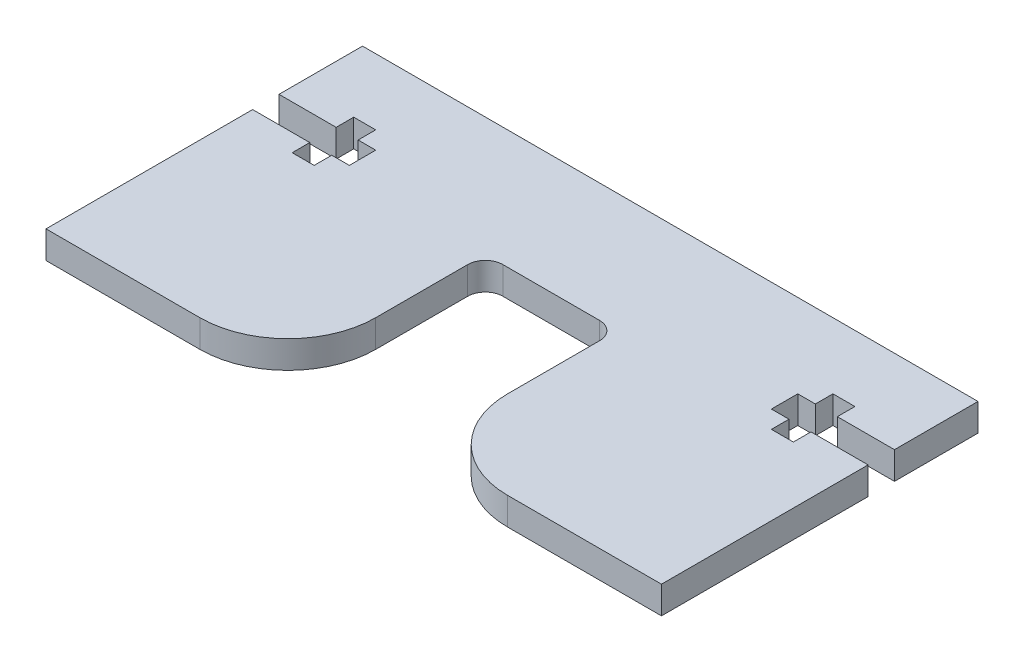
from build123d import *

# Parameters (mm, degrees)
BOSS_EXTRUDE1_DEPTH = 1.5625
SKETCH2_W           = 15
SKETCH2_H           = 22.4625
CUT_EXTRUDE1_DEPTH  = 4.125
FILLET1_R           = 10
FILLET2_R           = 2


with BuildPart() as part:
    # Sketch1 → Boss-Extrude1 (new body, symmetric)
    with BuildSketch(Plane(origin=(0, 0, 0), x_dir=(1, 0, 0), z_dir=(0, 1, 0))):
        Polygon((0, 36), (35, 36), (35, 26.5), (28.5, 26.5), (28.5, 28.5), (26, 28.5), (26, 26.5), (24, 26.5), (24, 23.5), (26, 23.5), (26, 21.5), (28.5, 21.5), (28.5, 23.5), (35, 23.5), (35, 0), (0, 0), align=None)
    boss_extrude1 = extrude(amount=BOSS_EXTRUDE1_DEPTH, both=True)

    # Mirror1: Boss-Extrude1 across plane
    add(boss_extrude1.mirror(Plane(origin=(0, 0, 0), x_dir=(0, 0, 1), z_dir=(1, 0, 0))))

    # Sketch2 → Cut-Extrude1 (cut, through all)
    with BuildSketch(Plane.XZ.offset(1.5625)):
        with Locations((0, -11.23125)):
            Rectangle(SKETCH2_W, SKETCH2_H)
    extrude(amount=-CUT_EXTRUDE1_DEPTH, mode=Mode.SUBTRACT)

    # Fillet1
    fillet1_edges = [part.edges().sort_by_distance(p)[0] for p in [
        (-7.5, 0, 0),
        (7.5, 0, 0),
    ]]
    fillet(fillet1_edges, radius=FILLET1_R)

    # Fillet2
    fillet2_edges = [part.edges().sort_by_distance(p)[0] for p in [
        (-7.5, 0, -22.4625),
        (7.5, 0, -22.4625),
    ]]
    fillet(fillet2_edges, radius=FILLET2_R)


solid = part.part
